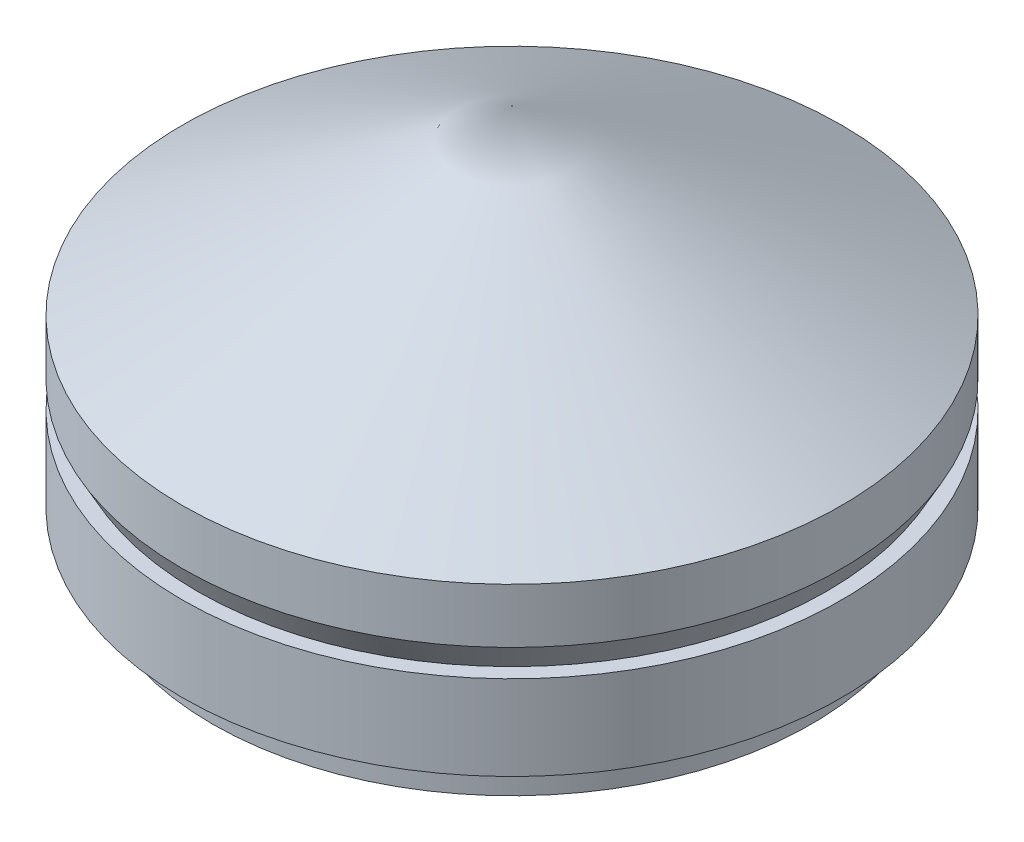
from build123d import *

# Parameters (mm, degrees)
SKETCH8_R           = 5.52
BOSS_EXTRUDE2_DEPTH = 0.7


with BuildPart() as part:
    # Sketch7 → Revolve1 (revolve)
    with BuildSketch(Plane.XY):
        Polygon((0, 55.134065354), (0, 48.724836522), (-6.075, 48.724836522), (-6.075, 50.284836522), (-5.8, 50.284836522), (-6.075, 50.784836522), (-6.075, 51.792815354), align=None)
    revolve(axis=Axis((0, 55.134065354, 0), (0, -1, 0)))

    # Sketch8 → Boss-Extrude2 (add)
    with BuildSketch(Plane.XZ.offset(-48.724836522)):
        Circle(SKETCH8_R)
    extrude(amount=BOSS_EXTRUDE2_DEPTH)


solid = part.part
